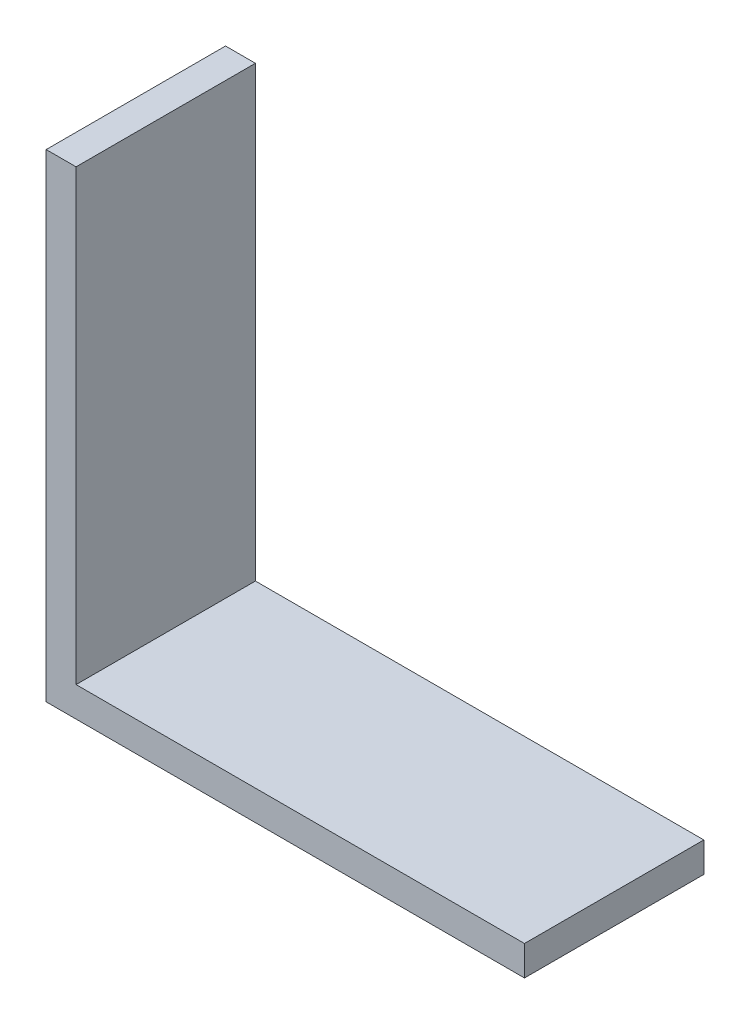
from build123d import *

# Parameters (mm, degrees)
BOSS_EXTRUDE1_DEPTH = 9.525


with BuildPart() as part:
    # Sketch1 → Boss-Extrude1 (new body, symmetric)
    with BuildSketch(Plane.XY):
        Polygon((0, 0), (0, 50.8), (3.175, 50.8), (3.175, 3.175), (50.8, 3.175), (50.8, 0), align=None)
    extrude(amount=BOSS_EXTRUDE1_DEPTH, both=True)


solid = part.part
